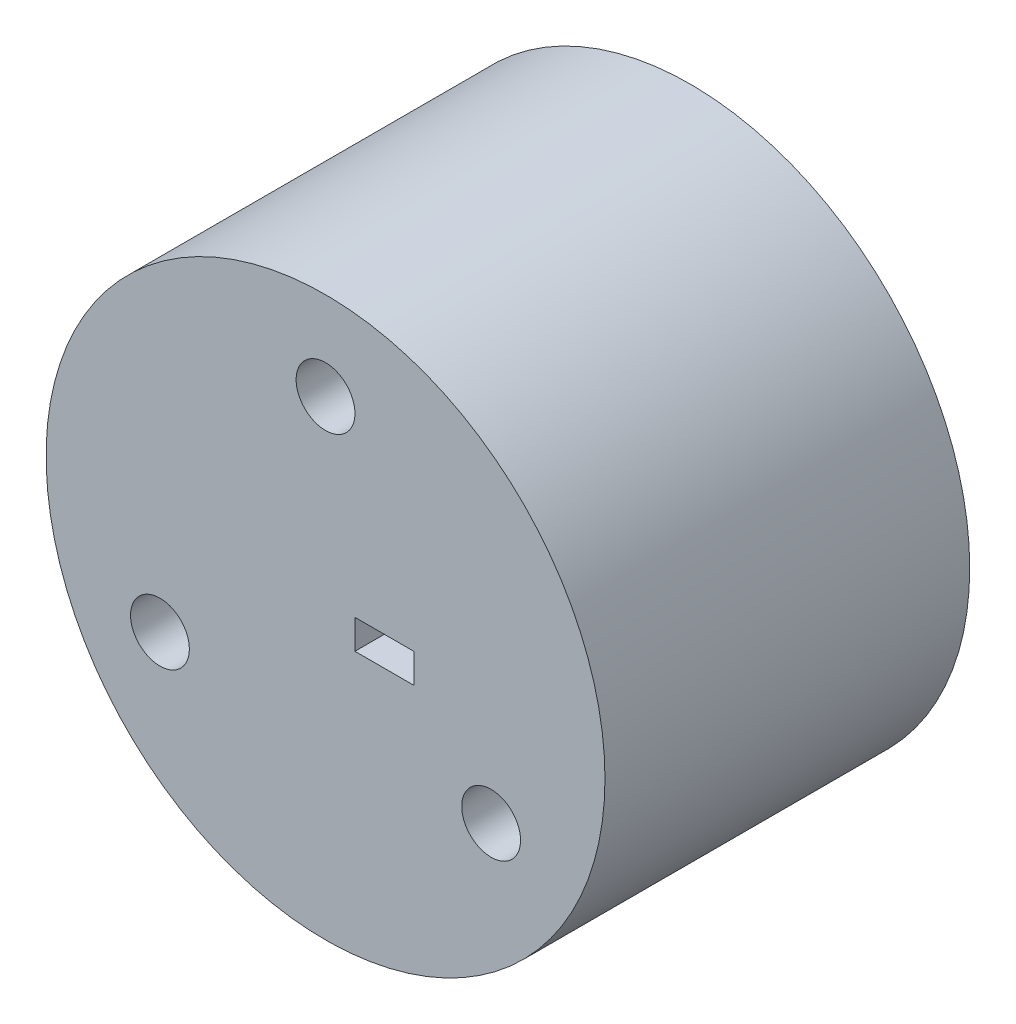
from build123d import *

# Parameters (mm, degrees)
SKETCH1_R           = 47.5
BOSS_EXTRUDE1_DEPTH = 62
SKETCH2_W           = 10
SKETCH2_H           = 5
CUT_EXTRUDE1_DEPTH  = 20
SKETCH3_R           = 5
CUT_EXTRUDE2_DEPTH  = 63


with BuildPart() as part:
    # Sketch1 → Boss-Extrude1 (new body)
    with BuildSketch(Plane.XY):
        Circle(SKETCH1_R)
    extrude(amount=BOSS_EXTRUDE1_DEPTH)

    # Sketch2 → Cut-Extrude1 (cut)
    with BuildSketch(Plane.XY.offset(62)):
        with Locations((10, 0)):
            Rectangle(SKETCH2_W, SKETCH2_H)
    extrude(amount=-CUT_EXTRUDE1_DEPTH, mode=Mode.SUBTRACT)

    # Sketch3 → Cut-Extrude2 (cut, through all)
    with BuildSketch(Plane.XY.offset(62)):
        with Locations((0, 32.5)):
            Circle(SKETCH3_R)
        with Locations((28.145825623, -16.25)):
            Circle(SKETCH3_R)
        with Locations((-28.145825623, -16.25)):
            Circle(SKETCH3_R)
    extrude(amount=-CUT_EXTRUDE2_DEPTH, mode=Mode.SUBTRACT)


solid = part.part
